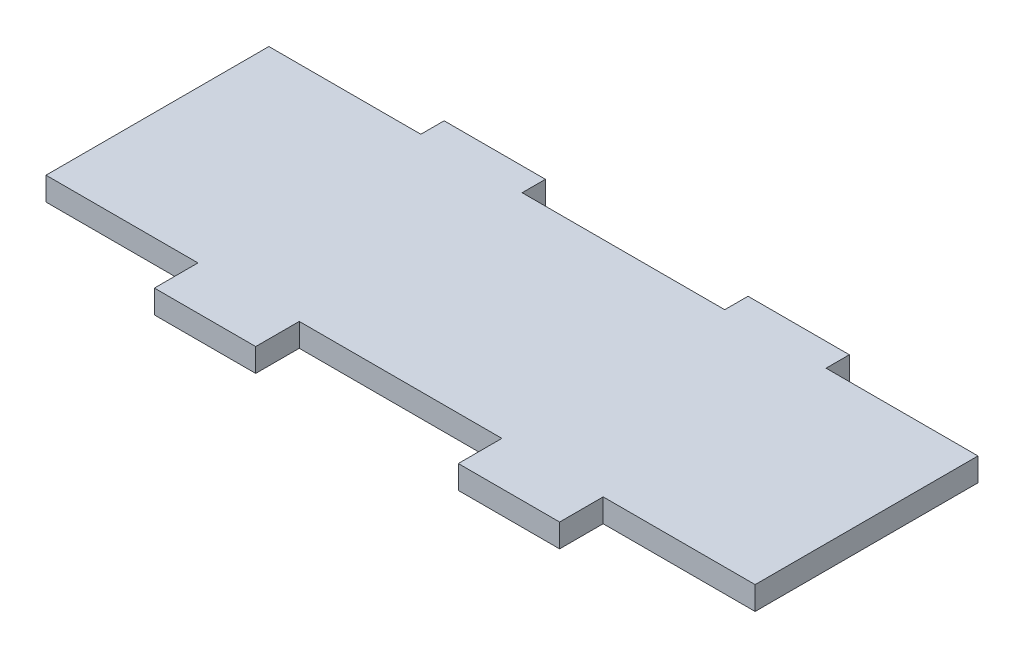
from build123d import *

# Parameters (mm, degrees)
BOSS_EXTRUDE1_DEPTH = 2.3


with BuildPart() as part:
    # Sketch1 → Boss-Extrude1 (new body)
    with BuildSketch(Plane(origin=(0, 0, 0), x_dir=(1, 0, 0), z_dir=(0, 1, 0))):
        Polygon((0, 0), (0, 22), (15, 22), (15, 24.3), (25, 24.3), (25, 22), (45, 22), (45, 24.3), (55, 24.3), (55, 22), (70, 22), (70, 0), (55, 0), (55, -4.3), (45, -4.3), (45, 0), (25, 0), (25, -4.3), (15, -4.3), (15, 0), align=None)
    extrude(amount=BOSS_EXTRUDE1_DEPTH)


solid = part.part
